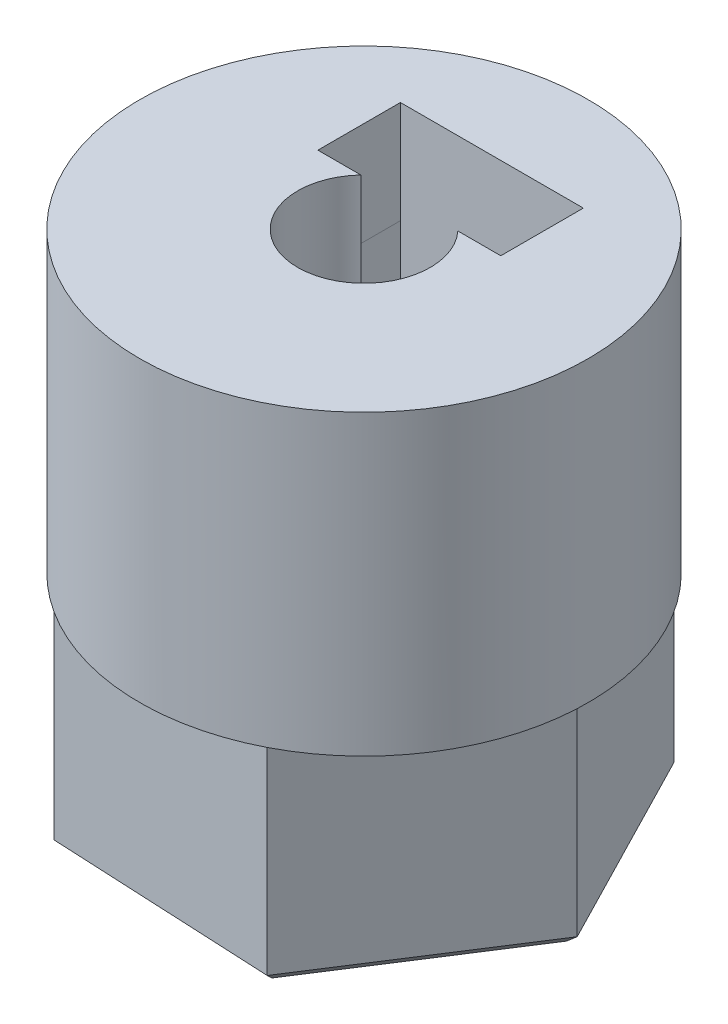
from build123d import *

# Parameters (mm, degrees)
BOSS_EXTRUDE1_DEPTH            = 6.4
SKETCH2_R                      = 6.92820323
BOSS_EXTRUDE2_DEPTH            = 9.2
SKETCH3_R                      = 1.65
CUT_EXTRUDE3_DEPTH             = 19.421726303
SKETCH4_W                      = 5.65
SKETCH4_H                      = 2.55
CUT_EXTRUDE4_DEPTH             = 6.4
CUT_EXTRUDE5_REACH             = 22.241
CUT_EXTRUDE5_DIRECTION_2_REACH = 22.241
CUT_EXTRUDE7_DEPTH             = 2.55
SKETCH3_4_R                    = 2.05
SKETCH3_4_R_2                  = 1.65
CUT_EXTRUDE8_DEPTH             = 9.4
CHAMFER1_SIZE                  = 0.3


with BuildPart() as part:
    # Sketch1 → Boss-Extrude1 (new body)
    with BuildSketch(Plane(origin=(0, 0, 0), x_dir=(1, 0, 0), z_dir=(0, 1, 0))):
        Polygon((3.170646703, -6.160113594), (6.920138214, -0.334196206), (3.749491511, 5.825917388), (-3.170646703, 6.160113594), (-6.920138214, 0.334196206), (-3.749491511, -5.825917388), align=None)
    extrude(amount=BOSS_EXTRUDE1_DEPTH)

    # Sketch2 → Boss-Extrude2 (add)
    with BuildSketch(Plane(origin=(0, 6.4, 0), x_dir=(1, 0, 0), z_dir=(0, 1, 0))):
        Circle(SKETCH2_R)
    extrude(amount=BOSS_EXTRUDE2_DEPTH)

    # Sketch3 → Cut-Extrude3 (cut, through all)
    with BuildSketch(Plane(origin=(0, 15.6, 0), x_dir=(1, 0, 0), z_dir=(0, 1, 0))):
        Circle(SKETCH3_R)
    extrude(amount=-CUT_EXTRUDE3_DEPTH, mode=Mode.SUBTRACT)

    # Sketch4 → Cut-Extrude4 (cut)
    with BuildSketch(Plane(origin=(0, 15.6, 0), x_dir=(1, 0, 0), z_dir=(0, 1, 0))):
        with Locations((0, 2.675)):
            Rectangle(SKETCH4_W, SKETCH4_H)
    extrude(amount=-CUT_EXTRUDE4_DEPTH, mode=Mode.SUBTRACT)

    # Sketch5 → Cut-Extrude5 (cut, up to next)
    with BuildSketch(Plane.XY.offset(-3.95), mode=Mode.PRIVATE) as cut_extrude5_sk1:
        with BuildLine():
            ThreePointArc((0, 12.3), (-1.060660172, 9.739339828), (1.5, 10.8))
            ThreePointArc((1.5, 10.8), (1.060660172, 11.860660172), (0, 12.3))
        make_face()
    cut_extrude5_tool1 = extrude(cut_extrude5_sk1.sketch, amount=-CUT_EXTRUDE5_REACH, mode=Mode.PRIVATE) & part.part
    add(cut_extrude5_tool1.solids().sort_by_distance((0, 10.8, -3.95))[0], mode=Mode.SUBTRACT)

    # Sketch5 → Cut-Extrude5 direction 2 (cut, up to next)
    with BuildSketch(Plane.XY.offset(-3.95), mode=Mode.PRIVATE) as cut_extrude5_direction_2_sk1:
        with BuildLine():
            ThreePointArc((0, 12.3), (-1.060660172, 9.739339828), (1.5, 10.8))
            ThreePointArc((1.5, 10.8), (1.060660172, 11.860660172), (0, 12.3))
        make_face()
    cut_extrude5_direction_2_tool1 = extrude(cut_extrude5_direction_2_sk1.sketch, amount=CUT_EXTRUDE5_DIRECTION_2_REACH, mode=Mode.PRIVATE) & part.part
    add(cut_extrude5_direction_2_tool1.solids().sort_by_distance((0, 10.8, -3.95))[0], mode=Mode.SUBTRACT)

    # Sketch7 → Cut-Extrude7 (cut)
    with BuildSketch(Plane.XY.offset(-3.95)):
        Polygon((-2.825, 12.437789047), (-2.830866921, 9.172372758), (-0.005866921, 7.534583711), (2.825, 9.162210953), (2.830866921, 12.427627242), (0.005866921, 14.065416289), align=None)
    extrude(amount=CUT_EXTRUDE7_DEPTH, mode=Mode.SUBTRACT)

    # Sketch3_4 → Cut-Extrude8 (cut)
    with BuildSketch(Plane(origin=(0, 15.6, 0), x_dir=(1, 0, 0), z_dir=(0, 1, 0))):
        Circle(SKETCH3_4_R)
        Circle(SKETCH3_4_R_2, mode=Mode.SUBTRACT)
    extrude(amount=-CUT_EXTRUDE8_DEPTH, mode=Mode.SUBTRACT)

    # Chamfer1
    chamfer1_edges = [part.edges().sort_by_distance(p)[0] for p in [
        (5.045392458, 0, 3.2471549),
        (5.334814862, 0, -2.745860591),
        (0.289422404, 0, -5.993015491),
        (-5.045392458, 0, -3.2471549),
        (-5.334814862, 0, 2.745860591),
        (-0.289422404, 0, 5.993015491),
        (-1.65, 0, 0),
    ]]
    chamfer(chamfer1_edges, length=CHAMFER1_SIZE)


solid = part.part
